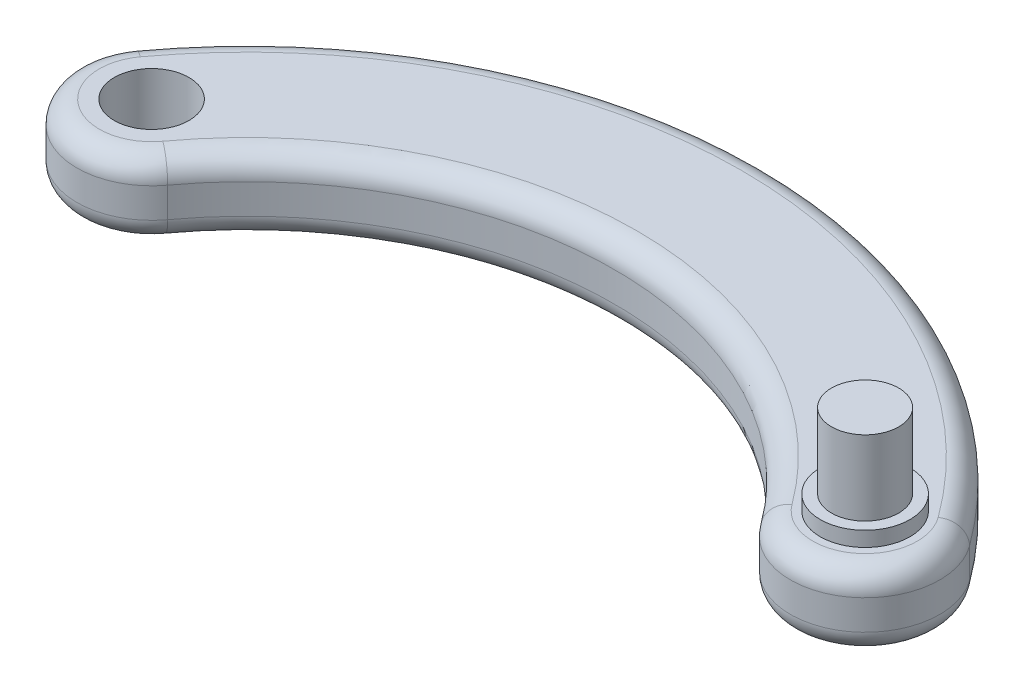
from build123d import *

# Parameters (mm, degrees)
SKETCH2_R           = 5
BOSS_EXTRUDE1_DEPTH = 10
FILLET1_R           = 3
SKETCH3_R           = 5
BOSS_EXTRUDE2_DEPTH = 10
SKETCH4_R           = 6
SKETCH4_R_2         = 4.5
BOSS_EXTRUDE3_DEPTH = 2
SKETCH6_R           = 4.5
BOSS_EXTRUDE4_DEPTH = 12


with BuildPart() as part:
    # Sketch2 → Boss-Extrude1 (new body)
    with BuildSketch(Plane(origin=(0, 0, 0), x_dir=(1, 0, 0), z_dir=(0, 1, 0))):
        with BuildLine():
            ThreePointArc((-8.065392234, -5.911805826), (5.911805826, -8.065392234), (8.065392234, 5.911805826))
            ThreePointArc((8.065392234, 5.911805826), (-47.75, 34.203568305), (-103.565392234, 5.911805826))
            ThreePointArc((-103.565392234, 5.911805826), (-101.411805826, -8.065392234), (-87.434607766, -5.911805826))
            ThreePointArc((-87.434607766, -5.911805826), (-47.75, 14.203568305), (-8.065392234, -5.911805826))
        make_face()
        with Locations((-95.5, 0)):
            Circle(SKETCH2_R, mode=Mode.SUBTRACT)
        Circle(SKETCH2_R, mode=Mode.SUBTRACT)
    extrude(amount=BOSS_EXTRUDE1_DEPTH)

    # Fillet1
    fillet1_edges = [part.edges().sort_by_distance(p)[0] for p in [
        (5.911805826, 10, 8.065392234),
        (-47.75, 10, -34.203568305),
        (-101.411805826, 10, 8.065392234),
        (-47.75, 10, -14.203568305),
        (-47.75, 0, -14.203568305),
        (-101.411805826, 0, 8.065392234),
        (-47.75, 0, -34.203568305),
        (5.911805826, 0, 8.065392234),
    ]]
    fillet(fillet1_edges, radius=FILLET1_R)

    # Sketch3 → Boss-Extrude2 (add)
    with BuildSketch(Plane(origin=(0, 10, 0), x_dir=(1, 0, 0), z_dir=(0, 1, 0))):
        Circle(SKETCH3_R)
    extrude(amount=-BOSS_EXTRUDE2_DEPTH)

    # Sketch4 → Boss-Extrude3 (add)
    with BuildSketch(Plane(origin=(0, 10, 0), x_dir=(1, 0, 0), z_dir=(0, 1, 0))):
        Circle(SKETCH4_R)
        Circle(SKETCH4_R_2, mode=Mode.SUBTRACT)
    extrude(amount=BOSS_EXTRUDE3_DEPTH)

    # Sketch6 → Boss-Extrude4 (add)
    with BuildSketch(Plane(origin=(0, 10, 0), x_dir=(1, 0, 0), z_dir=(0, 1, 0))):
        Circle(SKETCH6_R)
    extrude(amount=BOSS_EXTRUDE4_DEPTH)


solid = part.part
